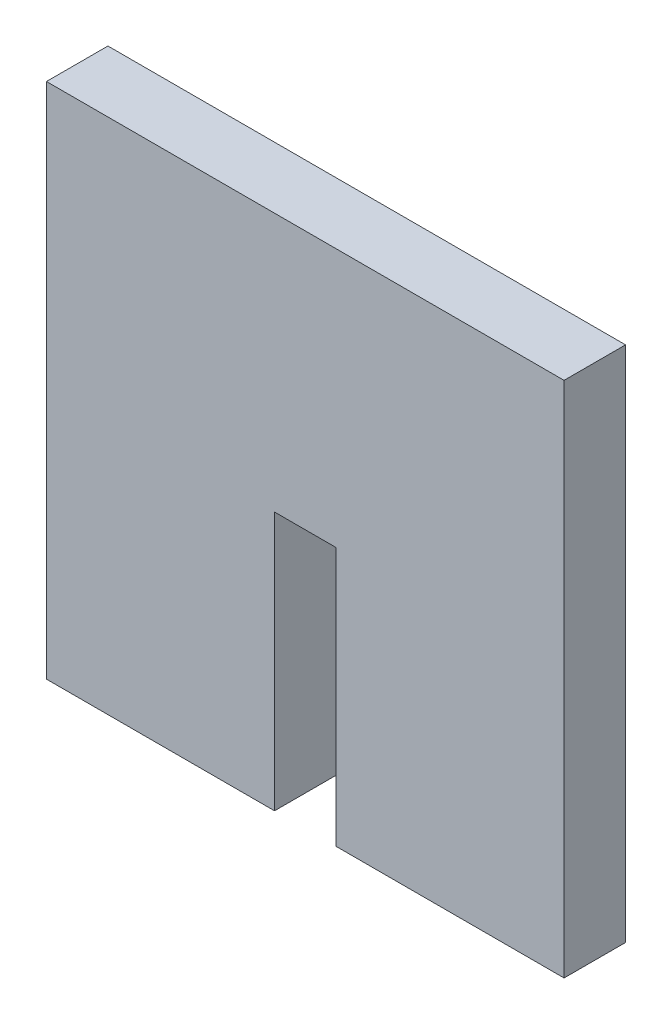
from build123d import *

# Parameters (mm, degrees)
BOSS_EXTRUDE1_DEPTH = 4.318


with BuildPart() as part:
    # Sketch1 → Boss-Extrude1 (new body)
    with BuildSketch(Plane.XY):
        Polygon((0, 0), (16.021, 0), (16.021, 18.18), (20.339, 18.18), (20.339, 0), (36.36, 0), (36.36, 36.36), (0, 36.36), align=None)
    extrude(amount=BOSS_EXTRUDE1_DEPTH)


solid = part.part
